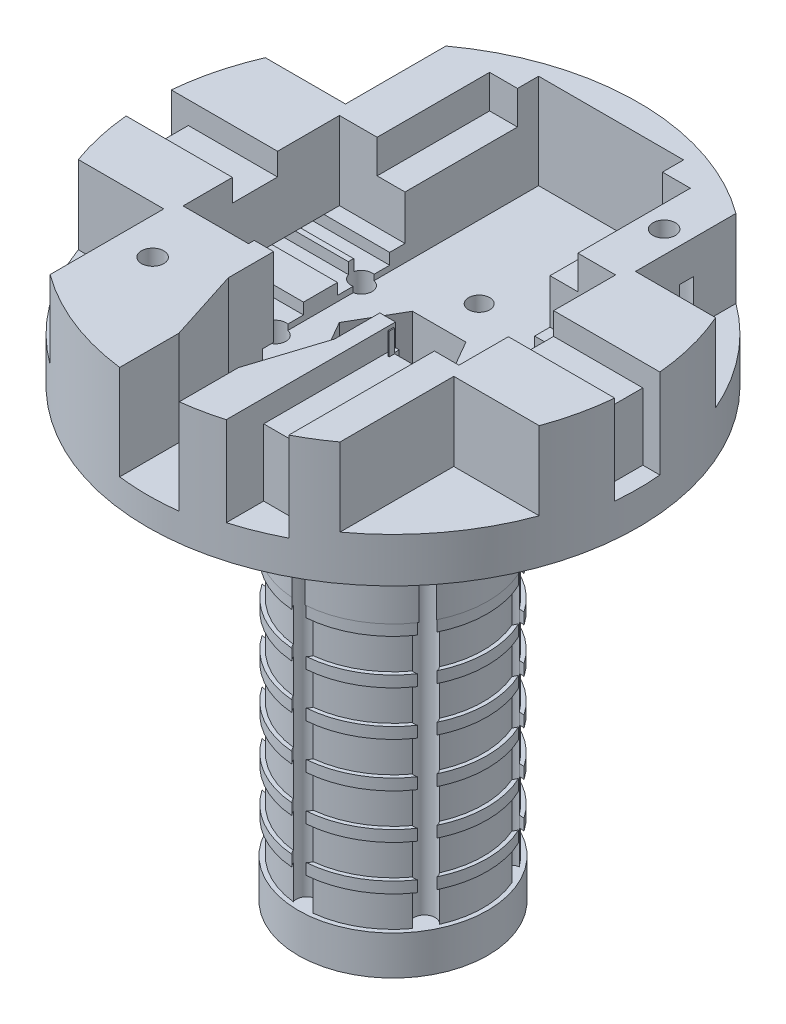
from build123d import *
from build123d.topology import SkipClean

# Parameters (mm, degrees)
BOSS_EXTRUDE1_DEPTH      = 9
BOSS_EXTRUDE1_DEPTH_BACK = 2
SKETCH1_R                = 22
SKETCH6_R                = 21
SKETCH6_R_2              = 12.5
CUT_EXTRUDE5_DEPTH       = 1
SKETCH7_R                = 8.5
BOSS_EXTRUDE2_DEPTH      = 40
CUT_EXTRUDE6_DEPTH       = 51.675437837
CUT_EXTRUDE6_DEPTH_BACK  = 51.675437837
SKETCH8_R                = 1.5
CUT_EXTRUDE7_DEPTH       = 7
SKETCH17_R               = 0.95
CUT_EXTRUDE14_DEPTH      = 62
SKETCH29_W               = 18
SKETCH29_H               = 24.118038922
CUT_EXTRUDE19_DEPTH      = 3
SKETCH30_W               = 2.5
SKETCH30_H               = 14
CUT_EXTRUDE20_DEPTH      = 6
BOSS_EXTRUDE4_DEPTH      = 2
BOSS_EXTRUDE4_DEPTH_BACK = 2
SKETCH35_R               = 9.1
SKETCH35_R_2             = 8.5
CUT_EXTRUDE28_DEPTH      = 1.5
CUT_EXTRUDE28_DEPTH_BACK = 1.5
SKETCH36_R               = 8.5
SKETCH36_R_2             = 8.1
CUT_EXTRUDE30_DEPTH      = 1.5
CUT_EXTRUDE30_DEPTH_BACK = 1.5
SKETCH39_R               = 8.5
SKETCH39_R_2             = 8.1
CUT_EXTRUDE31_DEPTH      = 1.5
CUT_EXTRUDE31_DEPTH_BACK = 1.5
SKETCH40_R               = 8.5
SKETCH40_R_2             = 8.1
CUT_EXTRUDE32_DEPTH      = 1.5
CUT_EXTRUDE32_DEPTH_BACK = 1.5
SKETCH41_R               = 8.5
SKETCH41_R_2             = 8.1
CUT_EXTRUDE33_DEPTH      = 1.5
CUT_EXTRUDE33_DEPTH_BACK = 1.5
SKETCH42_R               = 8.5
SKETCH42_R_2             = 8.1
CUT_EXTRUDE34_DEPTH      = 1.5
CUT_EXTRUDE34_DEPTH_BACK = 1.5
SKETCH43_R               = 8.5
SKETCH43_R_2             = 8.1
SKETCH47_W               = 27.732128476
SKETCH47_H               = 14.033639909
CUT_EXTRUDE38_DEPTH      = 7
CUT_EXTRUDE39_DEPTH      = 8.5
SKETCH48_R               = 1
CUT_EXTRUDE40_DEPTH      = 9
SKETCH50_R               = 6.388253867
BOSS_EXTRUDE5_DEPTH      = 2
SKETCH49_R               = 2.1
CUT_EXTRUDE42_DEPTH      = 7
CUT_EXTRUDE43_DEPTH      = 1
CUT_EXTRUDE44_DEPTH      = 2
CUT_EXTRUDE45_START      = -27.5
SKETCH53_R               = 8.5
SKETCH53_R_2             = 8.45
CUT_EXTRUDE45_DEPTH      = 27.5
CUT_EXTRUDE46_DEPTH      = 8
SKETCH55_W               = 1.737607108
SKETCH55_H               = 7.054348591
BOSS_EXTRUDE6_DEPTH      = 1
BOSS_EXTRUDE12_DEPTH     = 7
SKETCH57_W               = 10.391700465
SKETCH57_H               = 4.050234678
CUT_EXTRUDE49_DEPTH      = 2
CUT_EXTRUDE50_START      = -8
CUT_EXTRUDE50_DEPTH      = 8
BOSS_EXTRUDE13_START     = -3.5
SKETCH59_R               = 8.5
SKETCH59_R_2             = 4.95512383
BOSS_EXTRUDE13_DEPTH     = 3.5


with BuildPart() as part:
    # Sketch1 → Boss-Extrude1 (new, two sides: drawn at the far end of the back side and taken through both)
    with BuildSketch(Plane(origin=(0, 0, 0), x_dir=(1, 0, 0), z_dir=(0, 1, 0)).offset(-BOSS_EXTRUDE1_DEPTH_BACK)):
        Circle(SKETCH1_R)
    extrude(amount=BOSS_EXTRUDE1_DEPTH + BOSS_EXTRUDE1_DEPTH_BACK)

    # Sketch6 → Cut-Extrude5 (cut)
    with BuildSketch(Plane(origin=(0, -2, 0), x_dir=(-1, 0, 0), z_dir=(0, -1, 0))):
        Circle(SKETCH6_R)
        Circle(SKETCH6_R_2, mode=Mode.SUBTRACT)
    extrude(amount=-CUT_EXTRUDE5_DEPTH, mode=Mode.SUBTRACT)

    # Sketch7 → Boss-Extrude2 (add)
    with BuildSketch(Plane(origin=(0, -2, 0), x_dir=(-1, 0, 0), z_dir=(0, -1, 0))):
        Circle(SKETCH7_R)
    extrude(amount=BOSS_EXTRUDE2_DEPTH)

    # Sketch8 → Cut-Extrude6 (cut, two sides: drawn at the far end of the back side and taken through both)
    with BuildSketch(Plane(origin=(0, -2, 0), x_dir=(-1, 0, 0), z_dir=(0, -1, 0)).offset(-CUT_EXTRUDE6_DEPTH_BACK)):
        Circle(SKETCH8_R)
    extrude(amount=CUT_EXTRUDE6_DEPTH + CUT_EXTRUDE6_DEPTH_BACK, mode=Mode.SUBTRACT)

    # Sketch9 → Cut-Extrude7 (cut)
    with BuildSketch(Plane(origin=(0, 9, 0), x_dir=(1, 0, 0), z_dir=(0, 1, 0))):
        with BuildLine():
            Line((-13.000713231, -20.359249211), (-13.000713231, 20.359249211))
            ThreePointArc((-13.000713231, 20.359249211), (-24.156108398, 0), (-13.000713231, -20.359249211))
        make_face()
        with BuildLine():
            Line((13, -20.359704638), (13, 20.359704638))
            ThreePointArc((13, 20.359704638), (24.156108398, 0), (13, -20.359704638))
        make_face()
    extrude(amount=-CUT_EXTRUDE7_DEPTH, mode=Mode.SUBTRACT)

    # Sketch17 → Cut-Extrude14 (cut)
    with BuildSketch(Plane(origin=(0, -42, 0), x_dir=(-1, 0, 0), z_dir=(0, -1, 0))):
        with Locations((-6.69124665, 3.862786635)):
            Circle(SKETCH17_R)
        with Locations((-0.00035197, 7.7261829)):
            Circle(SKETCH17_R)
        with Locations((6.690894681, 3.863396264)):
            Circle(SKETCH17_R)
        with Locations((6.69124665, -3.862786635)):
            Circle(SKETCH17_R)
        with Locations((0.00035197, -7.7261829)):
            Circle(SKETCH17_R)
        with Locations((-6.690894681, -3.863396264)):
            Circle(SKETCH17_R)
        Polygon((4.811784194, -0.006803608), (2.411784194, 4.15011833), (-2.388215806, 4.15011833), (-4.788215806, -0.006803608), (-2.388215806, -4.163725546), (2.411784194, -4.163725546), align=None)
    extrude(amount=-CUT_EXTRUDE14_DEPTH, mode=Mode.SUBTRACT)

    # Sketch29 → Cut-Extrude19 (cut)
    with BuildSketch(Plane(origin=(0, 9, 0), x_dir=(1, 0, 0), z_dir=(0, 1, 0))):
        with Locations((0, 5.603215798)):
            Rectangle(SKETCH29_W, SKETCH29_H)
    extrude(amount=-CUT_EXTRUDE19_DEPTH, mode=Mode.SUBTRACT)

    # Sketch30 → Cut-Extrude20 (cut)
    with BuildSketch(Plane(origin=(0, 9, 0), x_dir=(1, 0, 0), z_dir=(0, 1, 0))):
        with Locations((6.752146467, 0.544196337)):
            Rectangle(SKETCH30_W, SKETCH30_H)
        with Locations((-6.752146467, 0.544196337)):
            Rectangle(SKETCH30_W, SKETCH30_H)
    extrude(amount=-CUT_EXTRUDE20_DEPTH, mode=Mode.SUBTRACT)

    # Sketch35 → Boss-Extrude4 (add, two sides: drawn at the far end of the back side and taken through both)
    with BuildSketch(Plane(origin=(0, -6.5, 0), x_dir=(1, 0, 0), z_dir=(0, 1, 0)).offset(-BOSS_EXTRUDE4_DEPTH_BACK)):
        Circle(SKETCH35_R)
        Circle(SKETCH35_R_2, mode=Mode.SUBTRACT)
    extrude(amount=BOSS_EXTRUDE4_DEPTH + BOSS_EXTRUDE4_DEPTH_BACK)

    # Sketch36 → Cut-Extrude28 (cut, two sides: drawn at the far end of the back side and taken through both)
    with BuildSketch(Plane(origin=(0, -17, 0), x_dir=(1, 0, 0), z_dir=(0, 1, 0)).offset(-CUT_EXTRUDE28_DEPTH_BACK)):
        Circle(SKETCH36_R)
        Circle(SKETCH36_R_2, mode=Mode.SUBTRACT)
    extrude(amount=CUT_EXTRUDE28_DEPTH + CUT_EXTRUDE28_DEPTH_BACK, mode=Mode.SUBTRACT)

    # Sketch39 → Cut-Extrude30 (cut, two sides: drawn at the far end of the back side and taken through both)
    with BuildSketch(Plane(origin=(0, -21, 0), x_dir=(1, 0, 0), z_dir=(0, 1, 0)).offset(-CUT_EXTRUDE30_DEPTH_BACK)):
        Circle(SKETCH39_R)
        Circle(SKETCH39_R_2, mode=Mode.SUBTRACT)
    extrude(amount=CUT_EXTRUDE30_DEPTH + CUT_EXTRUDE30_DEPTH_BACK, mode=Mode.SUBTRACT)

    # Sketch40 → Cut-Extrude31 (cut, two sides: drawn at the far end of the back side and taken through both)
    with BuildSketch(Plane(origin=(0, -25, 0), x_dir=(1, 0, 0), z_dir=(0, 1, 0)).offset(-CUT_EXTRUDE31_DEPTH_BACK)):
        Circle(SKETCH40_R)
        Circle(SKETCH40_R_2, mode=Mode.SUBTRACT)
    extrude(amount=CUT_EXTRUDE31_DEPTH + CUT_EXTRUDE31_DEPTH_BACK, mode=Mode.SUBTRACT)

    # Sketch41 → Cut-Extrude32 (cut, two sides: drawn at the far end of the back side and taken through both)
    with BuildSketch(Plane(origin=(0, -29, 0), x_dir=(1, 0, 0), z_dir=(0, 1, 0)).offset(-CUT_EXTRUDE32_DEPTH_BACK)):
        Circle(SKETCH41_R)
        Circle(SKETCH41_R_2, mode=Mode.SUBTRACT)
    extrude(amount=CUT_EXTRUDE32_DEPTH + CUT_EXTRUDE32_DEPTH_BACK, mode=Mode.SUBTRACT)

    # Sketch42 → Cut-Extrude33 (cut, two sides: drawn at the far end of the back side and taken through both)
    with BuildSketch(Plane(origin=(0, -33, 0), x_dir=(1, 0, 0), z_dir=(0, 1, 0)).offset(-CUT_EXTRUDE33_DEPTH_BACK)):
        Circle(SKETCH42_R)
        Circle(SKETCH42_R_2, mode=Mode.SUBTRACT)
    extrude(amount=CUT_EXTRUDE33_DEPTH + CUT_EXTRUDE33_DEPTH_BACK, mode=Mode.SUBTRACT)

    # Sketch43 → Cut-Extrude34 (cut, two sides: drawn at the far end of the back side and taken through both)
    with BuildSketch(Plane(origin=(0, -37, 0), x_dir=(1, 0, 0), z_dir=(0, 1, 0)).offset(-CUT_EXTRUDE34_DEPTH_BACK)):
        Circle(SKETCH43_R)
        Circle(SKETCH43_R_2, mode=Mode.SUBTRACT)
    extrude(amount=CUT_EXTRUDE34_DEPTH + CUT_EXTRUDE34_DEPTH_BACK, mode=Mode.SUBTRACT)

    # Sketch47 → Cut-Extrude38 (cut)
    with BuildSketch(Plane(origin=(0, 9, 0), x_dir=(1, 0, 0), z_dir=(0, 1, 0))):
        with Locations((-0.011675811, 0.561016292)):
            Rectangle(SKETCH47_W, SKETCH47_H)
    extrude(amount=-CUT_EXTRUDE38_DEPTH, mode=Mode.SUBTRACT)

    # Sketch23 → Cut-Extrude39 (cut)
    with BuildSketch(Plane(origin=(0, 9, 0), x_dir=(1, 0, 0), z_dir=(0, 1, 0))):
        with BuildLine():
            Line((-2.670420152, -16.85816067), (-2.670420152, -16.530371213))
            Line((-2.670420152, -16.530371213), (-4.762392892, -10))
            Line((-4.762392892, -10), (-4.762392892, -6.943148259))
            Line((-4.762392892, -6.943148259), (-6.5, -6.943148259))
            Line((-6.5, -6.943148259), (-6.5, 19.556851741))
            Line((-6.5, 19.556851741), (6.5, 19.556851741))
            Line((6.5, 19.556851741), (6.5, -6.943148259))
            Line((6.5, -6.943148259), (4.762392892, -6.943148259))
            Line((4.762392892, -6.943148259), (4.762392892, -10))
            Line((4.762392892, -10), (2.670420152, -16.530371213))
            Line((2.670420152, -16.530371213), (2.670420152, -16.85816067))
            Line((2.670420152, -16.85816067), (2.670420152, -21.837327131))
            ThreePointArc((2.670420152, -21.837327131), (1.836835043, -21.92318492), (1.000584871, -21.977234355))
            Line((1.000584871, -21.977234355), (0, -25.25))
            Line((0, -25.25), (-1.000584871, -21.977234355))
            ThreePointArc((-1.000584871, -21.977234355), (-1.836835043, -21.92318492), (-2.670420152, -21.837327131))
            Line((-2.670420152, -21.837327131), (-2.670420152, -16.85816067))
        make_face()
    extrude(amount=-CUT_EXTRUDE39_DEPTH, mode=Mode.SUBTRACT)

    # Sketch48 → Cut-Extrude40 (cut)
    with BuildSketch(Plane(origin=(0, 9, 0), x_dir=(1, 0, 0), z_dir=(0, 1, 0))):
        with Locations((11, 13.315197565)):
            Circle(SKETCH48_R)
        with Locations((-9.750356615, -11.802538605)):
            Circle(SKETCH48_R)
    extrude(amount=-CUT_EXTRUDE40_DEPTH, mode=Mode.SUBTRACT)

    # Sketch50 → Boss-Extrude5 (add)
    with BuildSketch(Plane.XZ.offset(42)):
        Circle(SKETCH50_R)
        Polygon((-4.989659815, -0.000576747), (-2.49433043, -4.321460529), (2.495329385, -4.320883782), (4.989659815, 0.000576747), (2.49433043, 4.321460529), (-2.495329385, 4.320883782), align=None, mode=Mode.SUBTRACT)
    extrude(amount=-BOSS_EXTRUDE5_DEPTH)

    # Sketch49 → Cut-Extrude42 (cut)
    with BuildSketch(Plane.XZ.offset(1)):
        with Locations((-9.750356615, 11.802538605)):
            Circle(SKETCH49_R)
        with Locations((11, -13.315197565)):
            Circle(SKETCH49_R)
    extrude(amount=-CUT_EXTRUDE42_DEPTH, mode=Mode.SUBTRACT)

    # Sketch51 → Cut-Extrude43 (cut)
    with BuildSketch(Plane(origin=(0, 2, 0), x_dir=(1, 0, 0), z_dir=(0, 1, 0))):
        Polygon((1.118766546, 6.2), (17.818651395, 6.2), (17.818651395, 4.1), (1.118766546, 4.1), (1.118766546, 3.625), (17.818651395, 3.625), (17.818651395, 1.525), (1.118766546, 1.525), (1.118766546, -1.525), (17.818651395, -1.525), (17.818651395, -3.625), (1.118766546, -3.625), (1.118766546, -4.1), (17.818651395, -4.1), (17.818651395, -6.2), (1.118766546, -6.2), (1.118766546, -10.984849516), (-1.118766546, -10.984849516), (-1.118766546, -6.2), (-17.818651395, -6.2), (-17.818651395, -4.1), (-1.118766546, -4.1), (-1.118766546, -3.625), (-17.818651395, -3.625), (-17.818651395, -1.525), (-1.118766546, -1.525), (-1.118766546, 1.525), (-17.818651395, 1.525), (-17.818651395, 3.625), (-1.118766546, 3.625), (-1.118766546, 4.1), (-17.818651395, 4.1), (-17.818651395, 6.2), (-1.118766546, 6.2), (-1.118766546, 10.984849516), (1.118766546, 10.984849516), align=None)
    extrude(amount=-CUT_EXTRUDE43_DEPTH, mode=Mode.SUBTRACT)

    # Sketch52 → Cut-Extrude44 (cut)
    with BuildSketch(Plane(origin=(0, 9, 0), x_dir=(1, 0, 0), z_dir=(0, 1, 0))):
        Polygon((6.167287474, -17.764425584), (10.167287474, -17.764425584), (10.167287474, -6.455803663), (6.6, -6.455803663), (6.6, -6.943148259), (6.167287474, -6.943148259), align=None)
    extrude(amount=-CUT_EXTRUDE44_DEPTH, mode=Mode.SUBTRACT)

    # Sketch53 → Cut-Extrude45 (cut)
    with BuildSketch(Plane.XZ.offset(42).offset(CUT_EXTRUDE45_START)):
        Circle(SKETCH53_R)
        Circle(SKETCH53_R_2, mode=Mode.SUBTRACT)
    extrude(amount=CUT_EXTRUDE45_DEPTH, mode=Mode.SUBTRACT)

    # Sketch54 → Cut-Extrude46 (cut)
    with BuildSketch(Plane(origin=(0, 9, 0), x_dir=(1, 0, 0), z_dir=(0, 1, 0))):
        with BuildLine():
            Line((10.167287474, -19.509645446), (10.167287474, -17.764425584))
            Line((10.167287474, -17.764425584), (6.167287474, -17.764425584))
            Line((6.167287474, -17.764425584), (6.167287474, -21.117873122))
            ThreePointArc((6.167287474, -21.117873122), (8.206776697, -20.411977274), (10.167287474, -19.509645446))
        make_face()
    extrude(amount=-CUT_EXTRUDE46_DEPTH, mode=Mode.SUBTRACT)

    # Sketch55 → Boss-Extrude6 (add)
    with BuildSketch(Plane(origin=(0, 0, 6.943148259), x_dir=(-1, 0, 0), z_dir=(0, 0, -1))):
        Polygon((-4.762392892, 9), (-6.167287474, 9), (-6.167287474, 7), (-6.5, 7), (-6.5, 1.945651409), (-4.762392892, 1.945651409), align=None)
        with Locations((5.631196446, 5.472825704)):
            Rectangle(SKETCH55_W, SKETCH55_H)
    extrude(amount=BOSS_EXTRUDE6_DEPTH)

    # Sketch56 → Boss-Extrude12 (add)
    with BuildSketch(Plane(origin=(0, 2, 0), x_dir=(1, 0, 0), z_dir=(0, 1, 0))):
        with BuildLine():
            Line((12.366479919, -7.551650053), (12.383760565, 8.742214933))
            Line((12.383760565, 8.742214933), (20.188454078, 8.742214933))
            ThreePointArc((20.188454078, 8.742214933), (21.990663147, 0.640885619), (20.663314871, -7.551650053))
            Line((20.663314871, -7.551650053), (12.366479919, -7.551650053))
        make_face()
    boss_extrude12 = extrude(amount=BOSS_EXTRUDE12_DEPTH)

    # Sketch57 → Cut-Extrude49 (cut)
    with BuildSketch(Plane(origin=(0, 9, 0), x_dir=(1, 0, 0), z_dir=(0, 1, 0))):
        with Locations((17.138887491, 0)):
            Rectangle(SKETCH57_W, SKETCH57_H)
    cut_extrude49 = extrude(amount=-CUT_EXTRUDE49_DEPTH, mode=Mode.SUBTRACT)

    # Sketch58 → Cut-Extrude50 (cut)
    with SkipClean():  # the faces are left unmerged after this step: merging them gives an invalid solid
        with BuildSketch(Plane(origin=(0, 9, 0), x_dir=(1, 0, 0), z_dir=(0, 1, 0)).offset(CUT_EXTRUDE50_START)):
            with BuildLine():
                Line((21.906594892, -2.025117339), (20.376461457, -2.025117339))
                Line((20.376461457, -2.025117339), (20.376461457, 2.025117339))
                Line((20.376461457, 2.025117339), (21.906594892, 2.025117339))
                ThreePointArc((21.906594892, 2.025117339), (22, 0), (21.906594892, -2.025117339))
            make_face()
        cut_extrude50 = extrude(amount=CUT_EXTRUDE50_DEPTH, mode=Mode.SUBTRACT)

    # Mirror1: Boss-Extrude12 across plane
    with SkipClean():  # the faces are left unmerged after this step: merging them gives an invalid solid
        add(boss_extrude12.mirror(Plane(origin=(0, 0, 0), x_dir=(0, 0, 1), z_dir=(1, 0, 0))))

    # Mirror2: Cut-Extrude49, Cut-Extrude50 across plane
    with SkipClean():  # the faces are left unmerged after this step: merging them gives an invalid solid
        add(cut_extrude49.mirror(Plane(origin=(0, 0, 0), x_dir=(0, 0, 1), z_dir=(1, 0, 0))), mode=Mode.SUBTRACT)
        add(cut_extrude50.mirror(Plane(origin=(0, 0, 0), x_dir=(0, 0, 1), z_dir=(1, 0, 0))), mode=Mode.SUBTRACT)

    # Sketch59 → Boss-Extrude13 (add)
    with SkipClean():  # the faces are left unmerged after this step: merging them gives an invalid solid
        with BuildSketch(Plane(origin=(0, -42, 0), x_dir=(-1, 0, 0), z_dir=(0, -1, 0)).offset(BOSS_EXTRUDE13_START)):
            Circle(SKETCH59_R)
            Circle(SKETCH59_R_2, mode=Mode.SUBTRACT)
        extrude(amount=BOSS_EXTRUDE13_DEPTH)


solid = part.part
